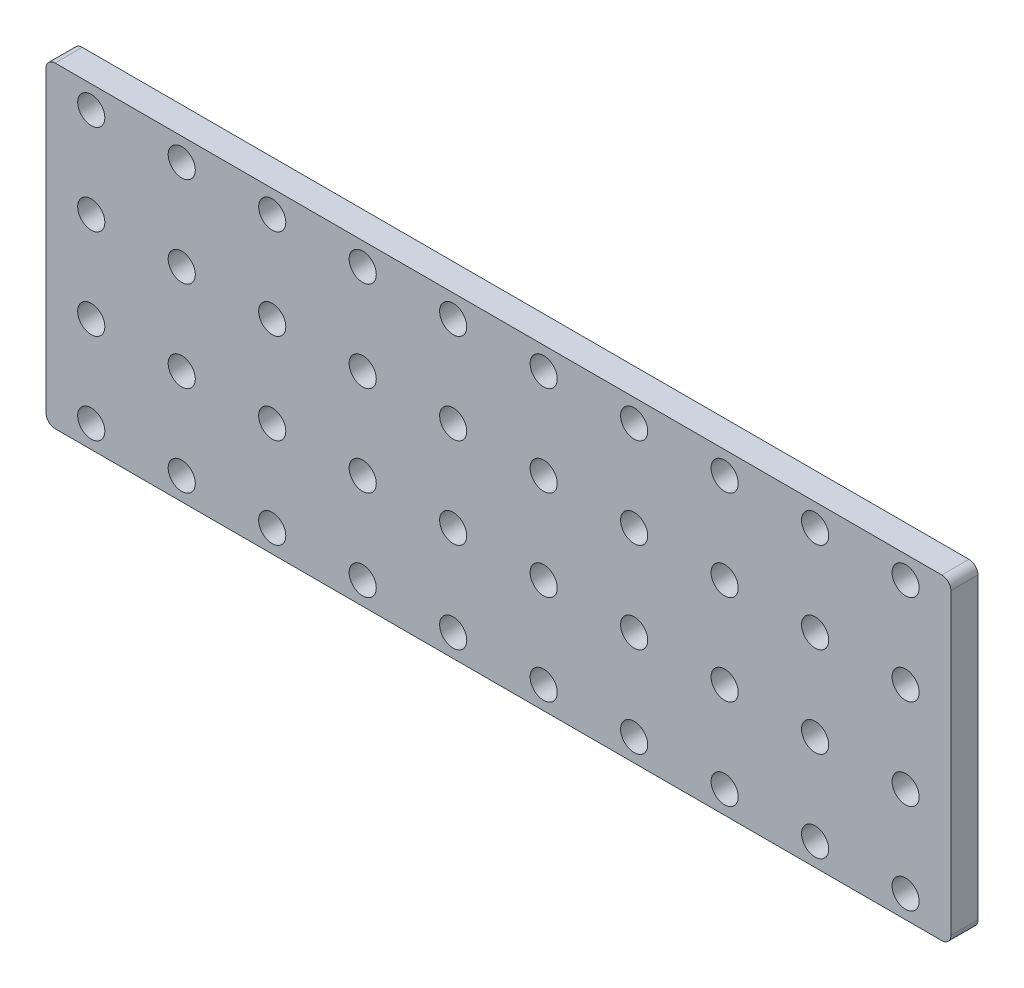
from build123d import *

# Parameters (mm, degrees)
ESQUISSE1_W             = 100
ESQUISSE1_H             = 35
BOSS_EXTRU_1_DEPTH      = 3
ESQUISSE2_R             = 1.5
ENL_V_MAT_EXTRU_1_DEPTH = 3
CONG_1_R                = 1


with BuildPart() as part:
    # Esquisse1 → Boss.-Extru.1 (new body)
    with BuildSketch(Plane.XY):
        with Locations((50, 17.5)):
            Rectangle(ESQUISSE1_W, ESQUISSE1_H)
    extrude(amount=BOSS_EXTRU_1_DEPTH)

    # Esquisse2 → Enlèv. mat.-Extru.1 (cut)
    with BuildSketch(Plane.XY.offset(3)):
        with Locations((95, 32.5)):
            Circle(ESQUISSE2_R)
        with Locations((85, 32.5)):
            Circle(ESQUISSE2_R)
        with Locations((75, 32.5)):
            Circle(ESQUISSE2_R)
        with Locations((65, 32.5)):
            Circle(ESQUISSE2_R)
        with Locations((55, 32.5)):
            Circle(ESQUISSE2_R)
        with Locations((45, 32.5)):
            Circle(ESQUISSE2_R)
        with Locations((35, 32.5)):
            Circle(ESQUISSE2_R)
        with Locations((25, 32.5)):
            Circle(ESQUISSE2_R)
        with Locations((15, 32.5)):
            Circle(ESQUISSE2_R)
        with Locations((5, 32.5)):
            Circle(ESQUISSE2_R)
        with Locations((85, 22.5)):
            Circle(ESQUISSE2_R)
        with Locations((75, 22.5)):
            Circle(ESQUISSE2_R)
        with Locations((65, 22.5)):
            Circle(ESQUISSE2_R)
        with Locations((55, 22.5)):
            Circle(ESQUISSE2_R)
        with Locations((45, 22.5)):
            Circle(ESQUISSE2_R)
        with Locations((35, 22.5)):
            Circle(ESQUISSE2_R)
        with Locations((25, 22.5)):
            Circle(ESQUISSE2_R)
        with Locations((15, 22.5)):
            Circle(ESQUISSE2_R)
        with Locations((5, 22.5)):
            Circle(ESQUISSE2_R)
        with Locations((85, 12.5)):
            Circle(ESQUISSE2_R)
        with Locations((75, 12.5)):
            Circle(ESQUISSE2_R)
        with Locations((65, 12.5)):
            Circle(ESQUISSE2_R)
        with Locations((55, 12.5)):
            Circle(ESQUISSE2_R)
        with Locations((45, 12.5)):
            Circle(ESQUISSE2_R)
        with Locations((35, 12.5)):
            Circle(ESQUISSE2_R)
        with Locations((25, 12.5)):
            Circle(ESQUISSE2_R)
        with Locations((15, 12.5)):
            Circle(ESQUISSE2_R)
        with Locations((5, 12.5)):
            Circle(ESQUISSE2_R)
        with Locations((85, 2.5)):
            Circle(ESQUISSE2_R)
        with Locations((75, 2.5)):
            Circle(ESQUISSE2_R)
        with Locations((65, 2.5)):
            Circle(ESQUISSE2_R)
        with Locations((55, 2.5)):
            Circle(ESQUISSE2_R)
        with Locations((45, 2.5)):
            Circle(ESQUISSE2_R)
        with Locations((35, 2.5)):
            Circle(ESQUISSE2_R)
        with Locations((25, 2.5)):
            Circle(ESQUISSE2_R)
        with Locations((15, 2.5)):
            Circle(ESQUISSE2_R)
        with Locations((5, 2.5)):
            Circle(ESQUISSE2_R)
        with Locations((95, 22.5)):
            Circle(ESQUISSE2_R)
        with Locations((95, 12.5)):
            Circle(ESQUISSE2_R)
        with Locations((95, 2.5)):
            Circle(ESQUISSE2_R)
    extrude(amount=-ENL_V_MAT_EXTRU_1_DEPTH, mode=Mode.SUBTRACT)

    # Congé1
    cong_1_edges = [part.edges().sort_by_distance(p)[0] for p in [
        (0, 35, 1.5),
        (100, 35, 1.5),
        (100, 0, 1.5),
        (0, 0, 1.5),
    ]]
    fillet(cong_1_edges, radius=CONG_1_R)


solid = part.part
